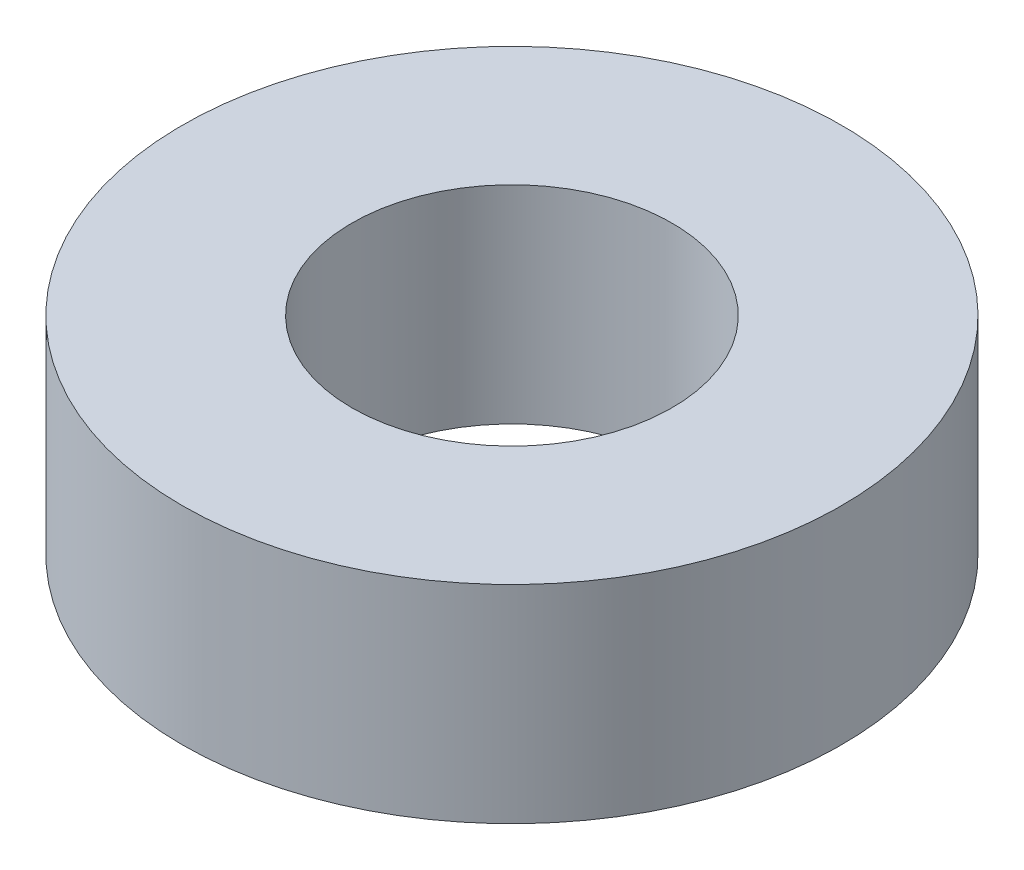
from build123d import *

# Parameters (mm, degrees)
SCHIZZO1_R                   = 17.5
SCHIZZO1_R_2                 = 8.5
ESTRUSIONE_ESTRUSIONE1_DEPTH = 11


with BuildPart() as part:
    # Schizzo1 → Estrusione-Estrusione1 (new body)
    with BuildSketch(Plane(origin=(0, 0, 0), x_dir=(1, 0, 0), z_dir=(0, 1, 0))):
        Circle(SCHIZZO1_R)
        Circle(SCHIZZO1_R_2, mode=Mode.SUBTRACT)
    extrude(amount=ESTRUSIONE_ESTRUSIONE1_DEPTH)


solid = part.part
